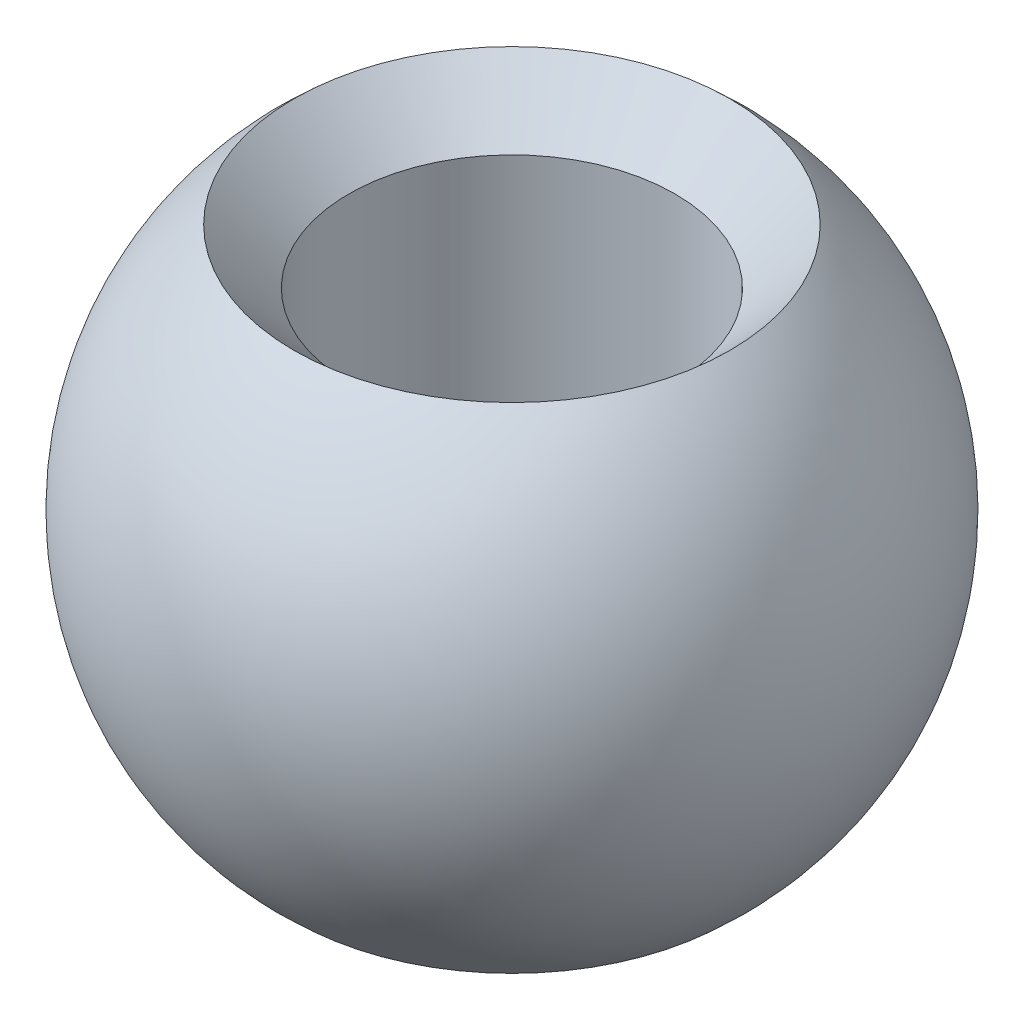
from build123d import *


with BuildPart() as part:
    # Sketch1 → Revolve4 (revolve)
    with BuildSketch(Plane.XY):
        with BuildLine():
            Line((-3.968626967, 4.5), (-2.968626967, 3.5))
            Line((-2.968626967, 3.5), (-2.968626967, -4.5))
            Line((-2.968626967, -4.5), (-3.968626967, -4.5))
            ThreePointArc((-3.968626967, -4.5), (-6, 0), (-3.968626967, 4.5))
        make_face()
    revolve(axis=Axis((0, -8.401347751, 0), (0, 1, 0)))


solid = part.part
